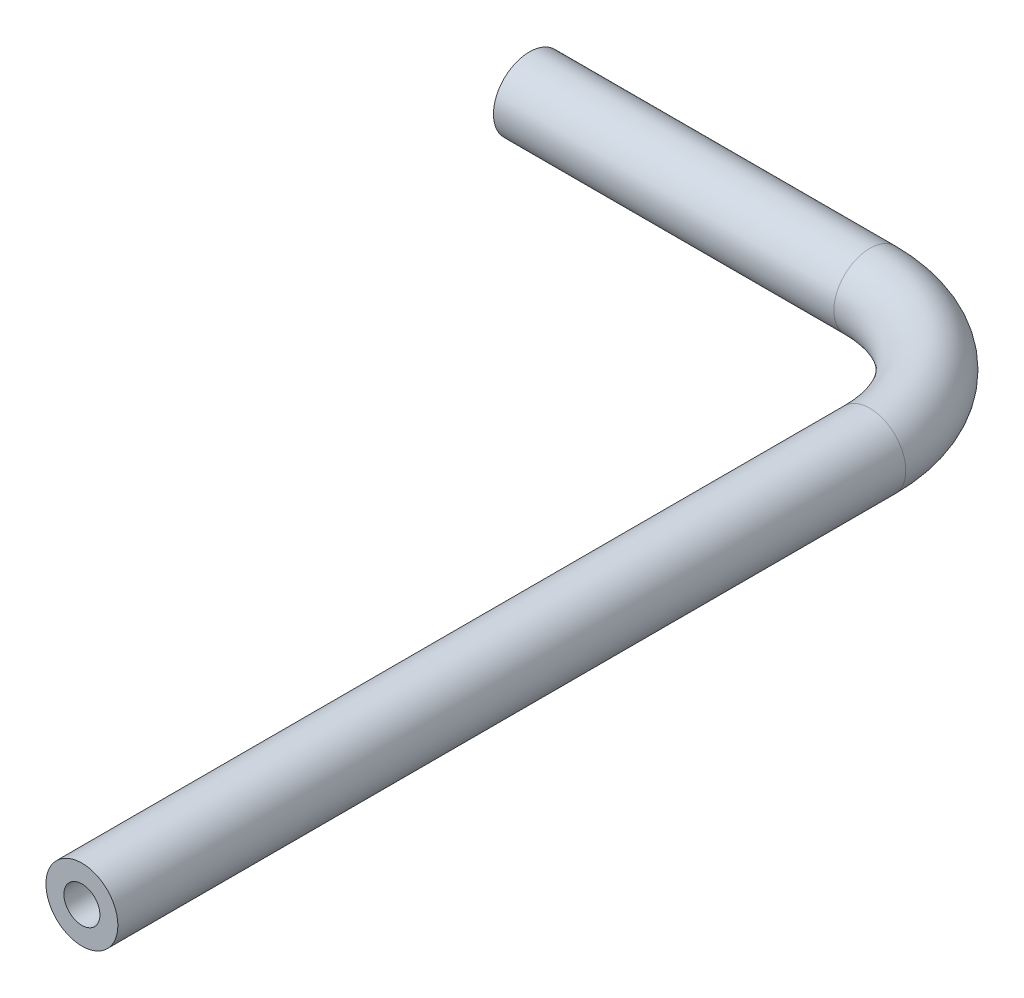
from build123d import *

# Parameters (mm, degrees)
SKETCH11_R   = 4.572
SKETCH11_R_2 = 2.286


with BuildPart() as part:
    # Sweep4: sweep along a path in Sketch10
    with BuildLine(Plane(origin=(0, 0, 0), x_dir=(1, 0, 0), z_dir=(0, 1, 0))) as sweep4_path:
        Line((60.859412379, -106.555716131), (60.859412379, -6.407929101))
        ThreePointArc((60.859412379, -6.407929101), (55.706644722, 6.03195246), (43.266763161, 11.184720116))
        Line((43.266763161, 11.184720116), (0, 11.184720116))
    # Sketch11 → Sweep4 (sweep)
    with BuildSketch(Plane(origin=(0, 0, 0), x_dir=(0, 0, -1), z_dir=(1, 0, 0))):
        with Locations((11.184720116, 0)):
            Circle(SKETCH11_R)
        with Locations((11.184720116, 0)):
            Circle(SKETCH11_R_2, mode=Mode.SUBTRACT)
    sweep(path=sweep4_path.line)


solid = part.part
